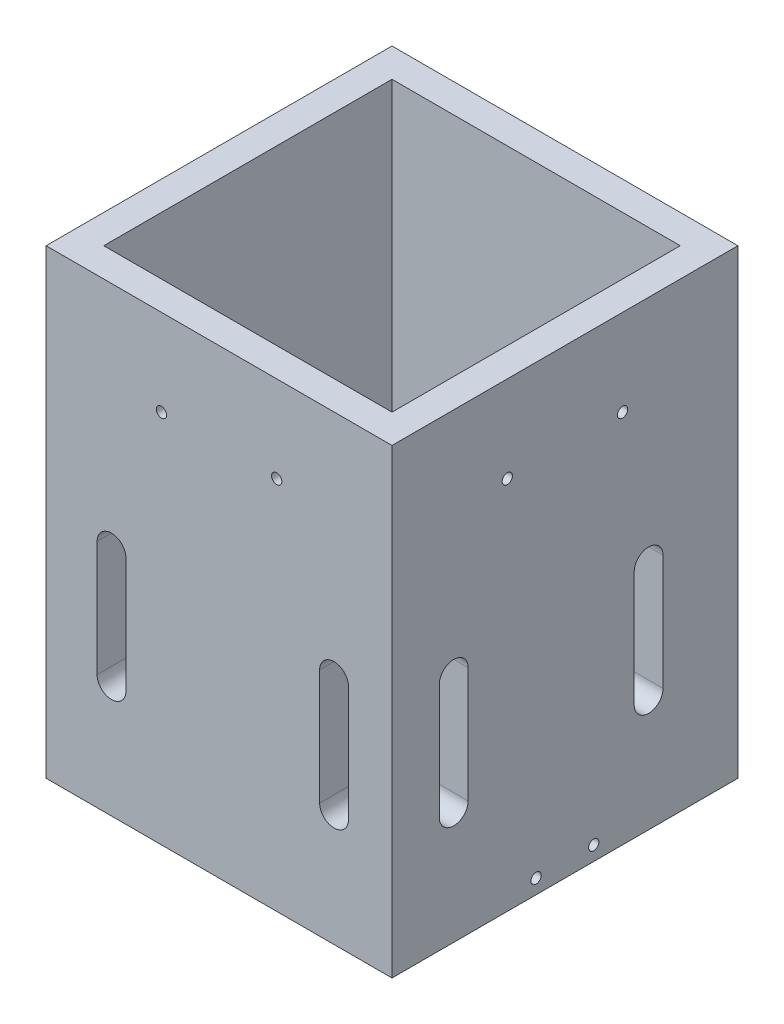
from build123d import *

# Parameters (mm, degrees)
SKETCH2_W                 = 76.2
SKETCH2_H                 = 76.2
BOSS_EXTRUDE1_DEPTH       = 101.6
SKETCH3_W                 = 63.5
SKETCH3_H                 = 63.5
CUT_EXTRUDE1_DEPTH        = 102.6
CUT_EXTRUDE2_REACH        = 78.2
CUT_EXTRUDE3_REACH        = 78.2
F_4_40_TAPPED_HOLE1_D     = 2.2606
F_4_40_TAPPED_HOLE1_DEPTH = 6.35
F_4_40_TAPPED_HOLE2_D     = 2.2606
F_4_40_TAPPED_HOLE2_DEPTH = 6.35
F_4_40_TAPPED_HOLE3_D     = 2.2606


with BuildPart() as part:
    # Sketch2 → Boss-Extrude1 (new body)
    with BuildSketch(Plane(origin=(0, 0, 0), x_dir=(1, 0, 0), z_dir=(0, 1, 0))):
        with Locations((-1.332167832, -5.151048951)):
            Rectangle(SKETCH2_W, SKETCH2_H)
    extrude(amount=BOSS_EXTRUDE1_DEPTH)

    # Sketch3 → Cut-Extrude1 (cut, through all)
    with BuildSketch(Plane(origin=(0, 101.6, 0), x_dir=(1, 0, 0), z_dir=(0, 1, 0))):
        with Locations((-1.332167832, -5.151048951)):
            Rectangle(SKETCH3_W, SKETCH3_H)
    extrude(amount=-CUT_EXTRUDE1_DEPTH, mode=Mode.SUBTRACT)

    # Sketch4 → Cut-Extrude2 (cut, up to next)
    with BuildSketch(Plane.XY.offset(43.251048951), mode=Mode.PRIVATE) as cut_extrude2_sk1:
        with BuildLine():
            Line((-28.192667832, 25.4), (-28.192667832, 50.8))
            ThreePointArc((-28.192667832, 50.8), (-25.017667832, 53.975), (-21.842667832, 50.8))
            Line((-21.842667832, 50.8), (-21.842667832, 25.4))
            ThreePointArc((-21.842667832, 25.4), (-25.017667832, 22.225), (-28.192667832, 25.4))
        make_face()
    cut_extrude2_tool1 = extrude(cut_extrude2_sk1.sketch, amount=-CUT_EXTRUDE2_REACH, mode=Mode.PRIVATE) & part.part
    add(cut_extrude2_tool1.solids().sort_by_distance((-25.017668, 38.1, 43.251049))[0], mode=Mode.SUBTRACT)
    # Sketch4 → Cut-Extrude2 (cut, up to next)
    with BuildSketch(Plane.XY.offset(43.251048951), mode=Mode.PRIVATE) as cut_extrude2_sk2:
        with BuildLine():
            Line((20.829332168, 25.4), (20.829332168, 50.8))
            ThreePointArc((20.829332168, 50.8), (24.004332168, 53.975), (27.179332168, 50.8))
            Line((27.179332168, 50.8), (27.179332168, 25.4))
            ThreePointArc((27.179332168, 25.4), (24.004332168, 22.225), (20.829332168, 25.4))
        make_face()
    cut_extrude2_tool2 = extrude(cut_extrude2_sk2.sketch, amount=-CUT_EXTRUDE2_REACH, mode=Mode.PRIVATE) & part.part
    add(cut_extrude2_tool2.solids().sort_by_distance((24.004332, 38.1, 43.251049))[0], mode=Mode.SUBTRACT)

    # Sketch5 → Cut-Extrude3 (cut, up to next)
    with BuildSketch(Plane(origin=(36.767832168, 0, 0), x_dir=(0, 0, -1), z_dir=(1, 0, 0)), mode=Mode.PRIVATE) as cut_extrude3_sk1:
        with BuildLine():
            Line((-32.824348951, 25.4), (-32.824348951, 50.8))
            ThreePointArc((-32.824348951, 50.8), (-29.649348951, 53.975), (-26.474348951, 50.8))
            Line((-26.474348951, 50.8), (-26.474348951, 25.4))
            ThreePointArc((-26.474348951, 25.4), (-29.649348951, 22.225), (-32.824348951, 25.4))
        make_face()
    cut_extrude3_tool1 = extrude(cut_extrude3_sk1.sketch, amount=-CUT_EXTRUDE3_REACH, mode=Mode.PRIVATE) & part.part
    add(cut_extrude3_tool1.solids().sort_by_distance((36.767832, 38.1, 29.649349))[0], mode=Mode.SUBTRACT)
    # Sketch5 → Cut-Extrude3 (cut, up to next)
    with BuildSketch(Plane(origin=(36.767832168, 0, 0), x_dir=(0, 0, -1), z_dir=(1, 0, 0)), mode=Mode.PRIVATE) as cut_extrude3_sk2:
        with BuildLine():
            Line((10.101651049, 25.4), (10.101651049, 50.8))
            ThreePointArc((10.101651049, 50.8), (13.276651049, 53.975), (16.451651049, 50.8))
            Line((16.451651049, 50.8), (16.451651049, 25.4))
            ThreePointArc((16.451651049, 25.4), (13.276651049, 22.225), (10.101651049, 25.4))
        make_face()
    cut_extrude3_tool2 = extrude(cut_extrude3_sk2.sketch, amount=-CUT_EXTRUDE3_REACH, mode=Mode.PRIVATE) & part.part
    add(cut_extrude3_tool2.solids().sort_by_distance((36.767832, 38.1, -13.276651))[0], mode=Mode.SUBTRACT)

    # #4-40 Tapped Hole1
    with Locations(Plane.XY.offset(43.251048951)):
        with Locations((-14.032167832, 82.55), (11.367832168, 82.55)):
            Hole(F_4_40_TAPPED_HOLE1_D / 2, depth=F_4_40_TAPPED_HOLE1_DEPTH)

    # #4-40 Tapped Hole2
    with Locations(Plane(origin=(36.767832168, 0, 0), x_dir=(0, 0, -1), z_dir=(1, 0, 0))):
        with Locations((-17.851048951, 82.55), (7.548951049, 82.55)):
            Hole(F_4_40_TAPPED_HOLE2_D / 2, depth=F_4_40_TAPPED_HOLE2_DEPTH)

    # #4-40 Tapped Hole3 (through all)
    with Locations(Plane(origin=(36.767832168, 0, 0), x_dir=(0, 0, -1), z_dir=(1, 0, 0))):
        with Locations((1.198951049, 3.175), (-11.501048951, 3.175)):
            Hole(F_4_40_TAPPED_HOLE3_D / 2)


solid = part.part
